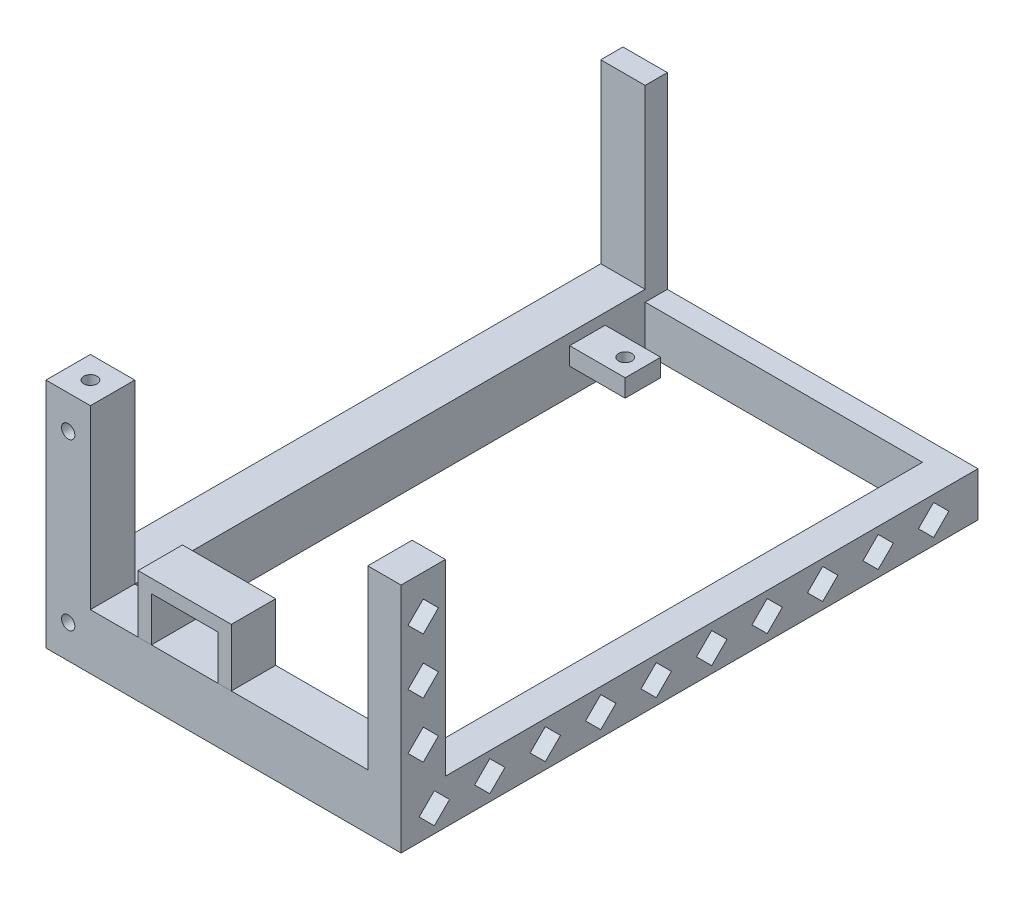
from build123d import *

# Parameters (mm, degrees)
SKETCH1_W           = 80
SKETCH1_H           = 130
BOSS_EXTRUDE1_DEPTH = 10
BOSS_EXTRUDE2_DEPTH = 42.3
CUT_EXTRUDE1_DEPTH  = 5.25
SKETCH4_R           = 1.5
CUT_EXTRUDE2_DEPTH  = 11
CUT_EXTRUDE3_DEPTH  = 11
SKETCH7_W           = 115
SKETCH7_H           = 39.8
CUT_EXTRUDE4_DEPTH  = 11
SKETCH8_W           = 62.5
SKETCH8_H           = 39.8
CUT_EXTRUDE5_DEPTH  = 10
SKETCH9_R           = 1.5
CUT_EXTRUDE6_DEPTH  = 4
SKETCH10_R          = 1.5
CUT_EXTRUDE7_DEPTH  = 4
SKETCH11_W          = 12.5
SKETCH11_H          = 8
CUT_EXTRUDE8_DEPTH  = 6
BOSS_EXTRUDE3_DEPTH = 10
SKETCH14_R          = 1.5
CUT_EXTRUDE9_DEPTH  = 4


with BuildPart() as part:
    # Sketch1 → Boss-Extrude1 (new body)
    with BuildSketch(Plane(origin=(0, 0, 0), x_dir=(1, 0, 0), z_dir=(0, 1, 0))):
        with Locations((-5, 0)):
            Rectangle(SKETCH1_W, SKETCH1_H)
    extrude(amount=BOSS_EXTRUDE1_DEPTH)

    # Sketch2 → Boss-Extrude2 (add)
    with BuildSketch(Plane(origin=(0, 10, 0), x_dir=(1, 0, 0), z_dir=(0, 1, 0))):
        Polygon((35, -65), (-45, -65), (-45, 65), (-35, 65), (-35, -55), (35, -55), align=None)
    extrude(amount=BOSS_EXTRUDE2_DEPTH)

    # Sketch3 → Cut-Extrude1 (cut)
    with BuildSketch(Plane(origin=(35, 0, 0), x_dir=(0, 0, -1), z_dir=(1, 0, 0))):
        Polygon((20.925, 5), (17.5, 8.425), (14.075, 5), (17.5, 1.575), align=None)
        Polygon((33.425, 5), (30, 8.425), (26.575, 5), (30, 1.575), align=None)
        Polygon((5, 8.425), (1.575, 5), (5, 1.575), (8.425, 5), align=None)
        Polygon((-4.075, 5), (-7.5, 8.425), (-10.925, 5), (-7.5, 1.575), align=None)
        Polygon((-16.575, 5), (-20, 8.425), (-23.425, 5), (-20, 1.575), align=None)
        Polygon((-29.075, 5), (-32.5, 8.425), (-35.925, 5), (-32.5, 1.575), align=None)
        Polygon((-41.575, 5), (-45, 8.425), (-48.425, 5), (-45, 1.575), align=None)
        Polygon((-54.075, 5), (-57.5, 8.425), (-60.925, 5), (-57.5, 1.575), align=None)
        Polygon((-63.425, 31.15), (-60, 34.575), (-56.575, 31.15), (-60, 27.725), align=None)
        Polygon((-60, 40.225), (-63.425, 43.65), (-60, 47.075), (-56.575, 43.65), align=None)
        Polygon((-60, 15.225), (-63.425, 18.65), (-60, 22.075), (-56.575, 18.65), align=None)
        Polygon((45.925, 5), (42.5, 8.425), (39.075, 5), (42.5, 1.575), align=None)
        Polygon((58.425, 5), (55, 8.425), (51.575, 5), (55, 1.575), align=None)
    extrude(amount=-CUT_EXTRUDE1_DEPTH, mode=Mode.SUBTRACT)

    # Sketch4 → Cut-Extrude2 (cut, through all)
    with BuildSketch(Plane(origin=(0, 10, 0), x_dir=(1, 0, 0), z_dir=(0, 1, 0))):
        with Locations((-26.5, 47)):
            Circle(SKETCH4_R)
    extrude(amount=-CUT_EXTRUDE2_DEPTH, mode=Mode.SUBTRACT)

    # Sketch5 → Cut-Extrude3 (cut, through all)
    with BuildSketch(Plane(origin=(0, 10, 0), x_dir=(1, 0, 0), z_dir=(0, 1, 0))):
        Polygon((-35, -55), (-35, 43), (-22.5, 43), (-22.5, 51), (-35, 51), (-35, 60), (27.5, 60), (27.5, -55), align=None)
    extrude(amount=-CUT_EXTRUDE3_DEPTH, mode=Mode.SUBTRACT)

    # Sketch7 → Cut-Extrude4 (cut, through all)
    with BuildSketch(Plane(origin=(-35, 0, 0), x_dir=(0, 0, -1), z_dir=(1, 0, 0))):
        with Locations((2.5, 32.4)):
            Rectangle(SKETCH7_W, SKETCH7_H)
    extrude(amount=-CUT_EXTRUDE4_DEPTH, mode=Mode.SUBTRACT)

    # Sketch8 → Cut-Extrude5 (cut)
    with BuildSketch(Plane(origin=(0, 0, 55), x_dir=(-1, 0, 0), z_dir=(0, 0, -1))):
        with Locations((3.75, 32.4)):
            Rectangle(SKETCH8_W, SKETCH8_H)
    extrude(amount=-CUT_EXTRUDE5_DEPTH, mode=Mode.SUBTRACT)

    # Sketch9 → Cut-Extrude6 (cut)
    with BuildSketch(Plane(origin=(0, 52.3, 0), x_dir=(1, 0, 0), z_dir=(0, 1, 0))):
        with Locations((-40, -60)):
            Circle(SKETCH9_R)
    extrude(amount=-CUT_EXTRUDE6_DEPTH, mode=Mode.SUBTRACT)

    # Sketch10 → Cut-Extrude7 (cut)
    with BuildSketch(Plane.XZ):
        with Locations((-40, 60)):
            Circle(SKETCH10_R)
    extrude(amount=-CUT_EXTRUDE7_DEPTH, mode=Mode.SUBTRACT)

    # Sketch11 → Cut-Extrude8 (cut)
    with BuildSketch(Plane.XZ):
        with Locations((-28.75, -47)):
            Rectangle(SKETCH11_W, SKETCH11_H)
    extrude(amount=-CUT_EXTRUDE8_DEPTH, mode=Mode.SUBTRACT)

    # Sketch14 → Cut-Extrude9 (cut)
    with BuildSketch(Plane.XY.offset(65)):
        with Locations((-40, 44.8)):
            Circle(SKETCH14_R)
        with Locations((-40, 7.5)):
            Circle(SKETCH14_R)
    extrude(amount=-CUT_EXTRUDE9_DEPTH, mode=Mode.SUBTRACT)


with BuildPart() as body_2:
    # Sketch13 → Boss-Extrude3 (new body)
    with BuildSketch(Plane.XY.offset(65)):
        Polygon((-24.25, 12.5), (-21.25, 12.5), (-21.25, 22.5), (-6.25, 22.5), (-6.25, 12.5), (-3.25, 12.5), (-3.25, 25.5), (-24.25, 25.5), align=None)
    extrude(amount=-BOSS_EXTRUDE3_DEPTH)


solid = Compound([part.part, body_2.part])
